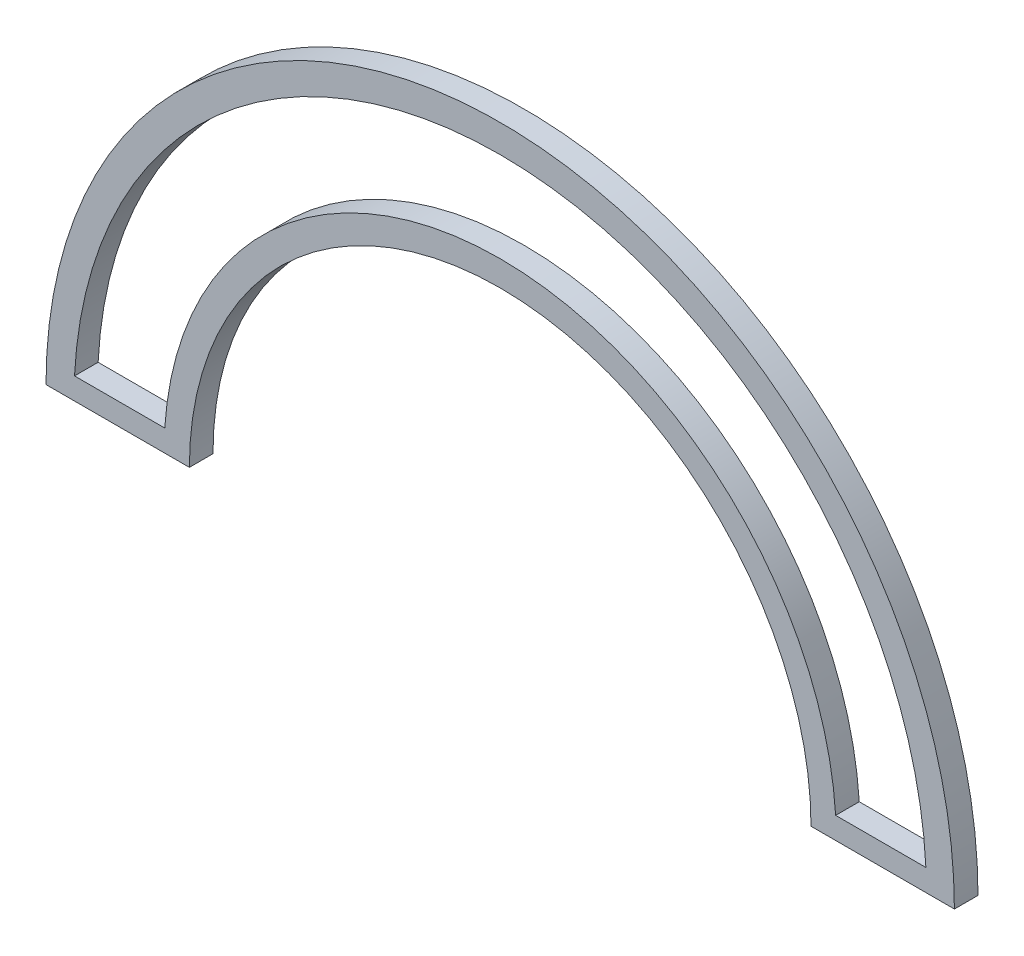
from build123d import *

# Parameters (mm, degrees)
BOSS_EXTRUDE1_DEPTH = 5


with BuildPart() as part:
    # Sketch1 → Boss-Extrude1 (new body)
    with BuildSketch(Plane.XY):
        with BuildLine():
            Line((-96.219647575, 0), (-65.846077968, 0))
            ThreePointArc((-65.846077968, 0), (0, 65.846077968), (65.846077968, 0))
            Line((65.846077968, 0), (96.219647575, 0))
            ThreePointArc((96.219647575, 0), (0, 96.219647575), (-96.219647575, 0))
        make_face()
        with BuildLine():
            Line((-90.181491194, 4.610764133), (-71.062529975, 4.610764133))
            ThreePointArc((-71.062529975, 4.610764133), (0, 71.211953437), (71.062529975, 4.610764133))
            Line((71.062529975, 4.610764133), (90.181491194, 4.610764133))
            ThreePointArc((90.181491194, 4.610764133), (0, 90.299282942), (-90.181491194, 4.610764133))
        make_face(mode=Mode.SUBTRACT)
    extrude(amount=BOSS_EXTRUDE1_DEPTH)


solid = part.part
